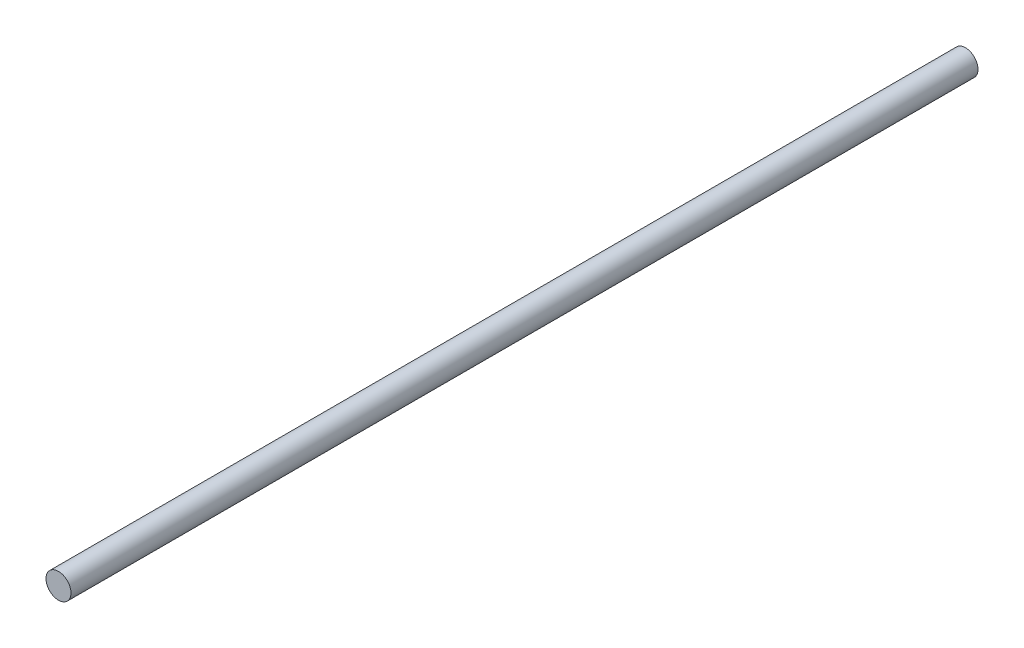
from build123d import *

# Parameters (mm, degrees)
SKETCH1_R           = 6.35
BOSS_EXTRUDE1_DEPTH = 460.502


with BuildPart() as part:
    # Sketch1 → Boss-Extrude1 (new body)
    with BuildSketch(Plane.XY):
        Circle(SKETCH1_R)
    extrude(amount=BOSS_EXTRUDE1_DEPTH)


solid = part.part
